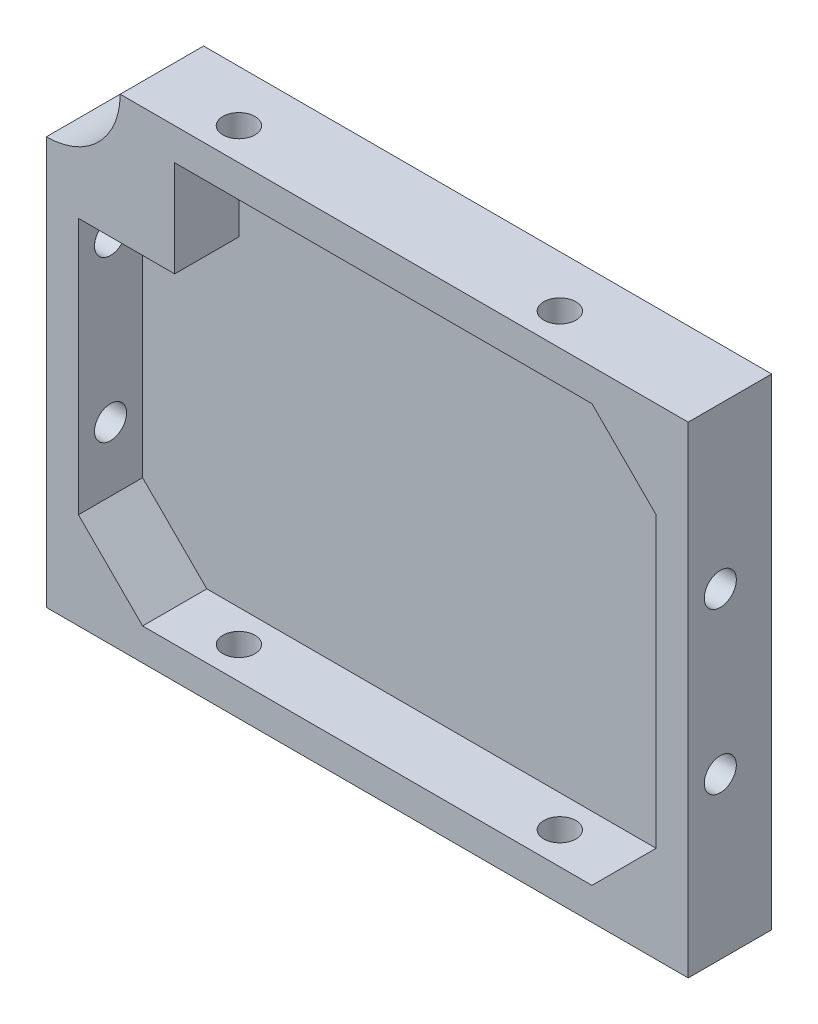
from build123d import *

# Parameters (mm, degrees)
BOSS_EXTRU_1_DEPTH        = 13
COQUE1_T                  = -5
COQUE1_THICKNESS_2_FACE_W = 90
COQUE1_THICKNESS_2_FACE_H = 65
COQUE1_THICKNESS_2_DEPTH  = 2
ENL_V_MAT_EXTRU_1_REACH   = 110.96
ESQUISSE2_R               = 2.5
ENL_V_MAT_EXTRU_2_REACH   = 95.396
ESQUISSE3_R               = 2.5
ESQUISSE4_W               = 15
ESQUISSE4_H               = 15
BOSS_EXTRU_2_DEPTH        = 10
ESQUISSE6_R               = 11.5
ENL_V_MAT_EXTRU_4_DEPTH   = 13


with BuildPart() as part:
    # Esquisse1 → Boss.-Extru.1 (new body)
    with BuildSketch(Plane.XY):
        Polygon((44.118436308, 33.728448276), (54.118436308, 33.728448276), (54.118436308, 23.728448276), (54.118436308, -41.271551724), (-45.881563692, -41.271551724), (-45.881563692, 33.728448276), align=None)
    extrude(amount=BOSS_EXTRU_1_DEPTH)

    # Coque1
    coque1_openings = [part.faces().sort_by_distance(p)[0] for p in [
        (4.118436308, -3.771551724, 13),
    ]]
    offset(amount=COQUE1_T, openings=coque1_openings, kind=Kind.INTERSECTION)

    # Coque1 thickness 2 face (on inner face of the shell) → Coque1 thickness 2 (cut)
    with BuildSketch(Plane(origin=(4.118436308, -3.771551724, 5), x_dir=(-1, 0, 0), z_dir=(0, 0, -1))):
        Rectangle(COQUE1_THICKNESS_2_FACE_W, COQUE1_THICKNESS_2_FACE_H)
    extrude(amount=COQUE1_THICKNESS_2_DEPTH, mode=Mode.SUBTRACT)

    # Enlèv. mat.-Extru.1: up to this face of the body (flat: up to its plane)
    enl_v_mat_extru_1_end = Plane(part.part.faces().sort_by_distance((54.118436308, -3.771551724, 6.5))[0])
    # Esquisse2 → Enlèv. mat.-Extru.1 (cut, up to the picked face)
    with BuildSketch(Plane.ZY.offset(45.881563692), mode=Mode.PRIVATE) as enl_v_mat_extru_1_sk1:
        with Locations(Location((8, -16.271551724, 0), (0, 0, 270))):
            Circle(ESQUISSE2_R)
    enl_v_mat_extru_1_tool1 = split(extrude(enl_v_mat_extru_1_sk1.sketch, amount=-ENL_V_MAT_EXTRU_1_REACH, mode=Mode.PRIVATE), bisect_by=enl_v_mat_extru_1_end, keep=Keep.BOTH, mode=Mode.PRIVATE)
    # Esquisse2 → Enlèv. mat.-Extru.1 (cut, up to the picked face)
    with BuildSketch(Plane.ZY.offset(45.881563692), mode=Mode.PRIVATE) as enl_v_mat_extru_1_sk2:
        with Locations(Location((8, 8.728448276, 0), (0, 0, 270))):
            Circle(ESQUISSE2_R)
    enl_v_mat_extru_1_tool2 = split(extrude(enl_v_mat_extru_1_sk2.sketch, amount=-ENL_V_MAT_EXTRU_1_REACH, mode=Mode.PRIVATE), bisect_by=enl_v_mat_extru_1_end, keep=Keep.BOTH, mode=Mode.PRIVATE)
    add(enl_v_mat_extru_1_tool1.solids().sort_by(Axis((-45.881564, -16.271552, 8), (1, 0, 0)))[0], mode=Mode.SUBTRACT)
    add(enl_v_mat_extru_1_tool2.solids().sort_by(Axis((-45.881564, 8.728448, 8), (1, 0, 0)))[0], mode=Mode.SUBTRACT)

    # Enlèv. mat.-Extru.2: up to this face of the body (flat: up to its plane)
    enl_v_mat_extru_2_end = Plane(part.part.faces().sort_by_distance((4.118436308, 33.728448276, 6.5))[0])
    # Esquisse3 → Enlèv. mat.-Extru.2 (cut, up to the picked face)
    with BuildSketch(Plane.XZ.offset(41.271551724), mode=Mode.PRIVATE) as enl_v_mat_extru_2_sk1:
        with Locations(Location((-20.881563692, 8, 0), (0, 0, 270))):
            Circle(ESQUISSE3_R)
    enl_v_mat_extru_2_tool1 = split(extrude(enl_v_mat_extru_2_sk1.sketch, amount=-ENL_V_MAT_EXTRU_2_REACH, mode=Mode.PRIVATE), bisect_by=enl_v_mat_extru_2_end, keep=Keep.BOTH, mode=Mode.PRIVATE)
    # Esquisse3 → Enlèv. mat.-Extru.2 (cut, up to the picked face)
    with BuildSketch(Plane.XZ.offset(41.271551724), mode=Mode.PRIVATE) as enl_v_mat_extru_2_sk2:
        with Locations(Location((29.118436308, 8, 0), (0, 0, 270))):
            Circle(ESQUISSE3_R)
    enl_v_mat_extru_2_tool2 = split(extrude(enl_v_mat_extru_2_sk2.sketch, amount=-ENL_V_MAT_EXTRU_2_REACH, mode=Mode.PRIVATE), bisect_by=enl_v_mat_extru_2_end, keep=Keep.BOTH, mode=Mode.PRIVATE)
    add(enl_v_mat_extru_2_tool1.solids().sort_by(Axis((-20.881564, -41.271552, 8), (0, 1, 0)))[0], mode=Mode.SUBTRACT)
    add(enl_v_mat_extru_2_tool2.solids().sort_by(Axis((29.118436, -41.271552, 8), (0, 1, 0)))[0], mode=Mode.SUBTRACT)

    # Esquisse4 → Boss.-Extru.2 (add)
    with BuildSketch(Plane.XY.offset(3)):
        Polygon((-30.881563692, -36.271551724), (-40.881563692, -26.271551724), (-40.881563692, -36.271551724), align=None)
        Polygon((49.118436308, 28.728448276), (49.118436308, 18.728448276), (39.118436308, 28.728448276), align=None)
        Polygon((49.118436308, -36.271551724), (49.118436308, -26.271551724), (39.118436308, -36.271551724), align=None)
        with Locations((-33.381563692, 21.228448276)):
            Rectangle(ESQUISSE4_W, ESQUISSE4_H)
    extrude(amount=BOSS_EXTRU_2_DEPTH)

    # Esquisse6 → Enlèv. mat.-Extru.4 (cut)
    with BuildSketch(Plane.XY.offset(13)):
        with Locations((-45.881563692, 33.728448276)):
            Circle(ESQUISSE6_R)
    extrude(amount=-ENL_V_MAT_EXTRU_4_DEPTH, mode=Mode.SUBTRACT)


solid = part.part
